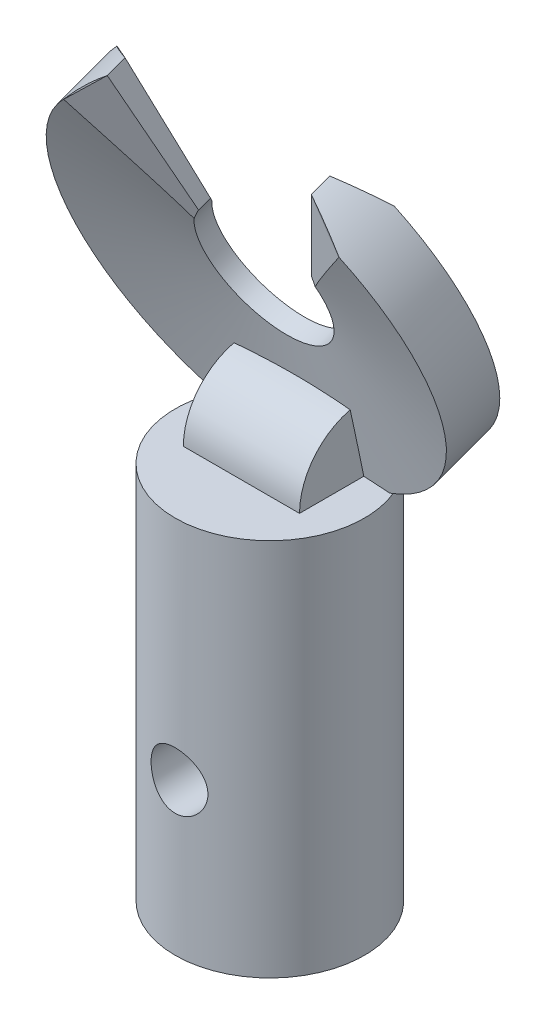
from build123d import *

# Parameters (mm, degrees)
SKETCH1_W                    = 30
SKETCH1_H                    = 30
BOSS_EXTRUDE1_DEPTH          = 3
SKETCH2_R                    = 5
BOSS_EXTRUDE2_DEPTH          = 55
CUT_EXTRUDE2_DEPTH           = 55
CUT_EXTRUDE3_DEPTH           = 7
CUT_EXTRUDE3_TAPER           = -9
CUT_EXTRUDE3_OTHER_WAY_DEPTH = 2
CUT_EXTRUDE4_DEPTH           = 7
CUT_EXTRUDE4_TAPER           = -9
CUT_EXTRUDE4_OTHER_WAY_DEPTH = 2
CUT_EXTRUDE4_OTHER_WAY_TAPER = -9
SKETCH11_W                   = 42.456870871
SKETCH11_H                   = 39.887112897
CUT_EXTRUDE5_DEPTH           = 16
CUT_EXTRUDE5_DEPTH_BACK      = 16
SKETCH12_W                   = 30
SKETCH12_H                   = 30
BOSS_EXTRUDE3_DEPTH          = 3
SKETCH13_W                   = 6.134758984
SKETCH13_H                   = 3.5
REVOLVE3_ANGLE               = 90
SKETCH14_W                   = 34.327932252
SKETCH14_H                   = 34.043423274
CUT_EXTRUDE6_DEPTH           = 3.3
SKETCH17_R                   = 2
CUT_EXTRUDE7_DEPTH           = 18
SKETCH18_R                   = 1.5
CUT_EXTRUDE8_DEPTH           = 8
CUT_EXTRUDE8_DEPTH_BACK      = 4


with BuildPart() as part:
    # Sketch1 → Boss-Extrude1 (new body)
    with BuildSketch(Plane(origin=(0, 0, 0), x_dir=(1, 0, 0), z_dir=(0, 1, 0))):
        Rectangle(SKETCH1_W, SKETCH1_H)
    extrude(amount=BOSS_EXTRUDE1_DEPTH)

    # Sketch2 → Boss-Extrude2 (add)
    with BuildSketch(Plane(origin=(0, 3, 0), x_dir=(1, 0, 0), z_dir=(0, 1, 0))):
        with Locations((0, -2)):
            Circle(SKETCH2_R)
    extrude(amount=BOSS_EXTRUDE2_DEPTH)

    # Sketch4 → Revolve1 (revolve)
    with BuildSketch(Plane(origin=(0, 0, 0), x_dir=(0, 0, -1), z_dir=(1, 0, 0))):
        Polygon((2.995694392, 58.01182956), (0.17661653, 56.98576913), (-1.106821781, 63.435791308), (-0.16712916, 63.777811451), align=None)
    revolve(axis=Axis((0, 68.333514617, -2.116247015), (0, -0.342020143, 0.939692621)))

    # Sketch5 → Cut-Extrude2 (cut)
    with BuildSketch(Plane(origin=(0, 7.748892564, -21.289907346), x_dir=(1, 0, 0), z_dir=(0, 0.342020143, -0.939692621))):
        Polygon((-3, -65.291475968), (-6.572175958, -75.105948751), (6.572175958, -75.105948751), (3, -65.291475968), align=None)
    extrude(amount=-CUT_EXTRUDE2_DEPTH, mode=Mode.SUBTRACT)

    # Sketch6 → Cut-Extrude3 (cut)
    with BuildSketch(Plane(origin=(37.638193634, 42.150337699, 15.341468287), x_dir=(0, -0.342020143, 0.939692621), z_dir=(0.64278761, 0.71984631, 0.26200263))):
        Polygon((-22.656246175, -42.076297889), (-21.656246175, -42.076297889), (-22.656246175, -39.576297889), align=None)
        Polygon((-19.616275943, -42.076297889), (-19.616275943, -39.576297889), (-20.616275943, -42.076297889), align=None)
    extrude(amount=-CUT_EXTRUDE3_DEPTH, taper=CUT_EXTRUDE3_TAPER, mode=Mode.SUBTRACT)

    # Sketch6 → Cut-Extrude3 other way (cut)
    with BuildSketch(Plane(origin=(37.638193634, 42.150337699, 15.341468287), x_dir=(0, -0.342020143, 0.939692621), z_dir=(0.64278761, 0.71984631, 0.26200263))):
        Polygon((-22.656246175, -42.076297889), (-21.656246175, -42.076297889), (-22.656246175, -39.576297889), align=None)
        Polygon((-19.616275943, -42.076297889), (-19.616275943, -39.576297889), (-20.616275943, -42.076297889), align=None)
    extrude(amount=CUT_EXTRUDE3_OTHER_WAY_DEPTH, mode=Mode.SUBTRACT)

    # Sketch8 → Cut-Extrude4 (cut)
    with BuildSketch(Plane(origin=(-37.638193634, 42.150337699, 15.341468287), x_dir=(0, 0.342020143, -0.939692621), z_dir=(0.64278761, -0.71984631, -0.26200263))):
        Polygon((22.656246175, 42.076297889), (21.656246175, 42.076297889), (22.656246175, 39.576297889), align=None)
        Polygon((20.656246175, 42.076297889), (19.656246175, 42.076297889), (19.656246175, 39.576297889), align=None)
    extrude(amount=CUT_EXTRUDE4_DEPTH, taper=CUT_EXTRUDE4_TAPER, mode=Mode.SUBTRACT)

    # Sketch8 → Cut-Extrude4 other way (cut)
    with BuildSketch(Plane(origin=(-37.638193634, 42.150337699, 15.341468287), x_dir=(0, 0.342020143, -0.939692621), z_dir=(0.64278761, -0.71984631, -0.26200263))):
        Polygon((22.656246175, 42.076297889), (21.656246175, 42.076297889), (22.656246175, 39.576297889), align=None)
        Polygon((20.656246175, 42.076297889), (19.656246175, 42.076297889), (19.656246175, 39.576297889), align=None)
    extrude(amount=-CUT_EXTRUDE4_OTHER_WAY_DEPTH, taper=CUT_EXTRUDE4_OTHER_WAY_TAPER, mode=Mode.SUBTRACT)

    # Sketch11 → Cut-Extrude5 (cut, two sides)
    with BuildSketch(Plane(origin=(0, 0, 0), x_dir=(0, 0, -1), z_dir=(1, 0, 0))) as cut_extrude5_sk:
        with Locations((2.849079493, 17.75767337)):
            Rectangle(SKETCH11_W, SKETCH11_H)
    extrude(amount=CUT_EXTRUDE5_DEPTH, mode=Mode.SUBTRACT)
    extrude(cut_extrude5_sk.sketch, amount=-CUT_EXTRUDE5_DEPTH_BACK, mode=Mode.SUBTRACT)

    # Sketch12 → Boss-Extrude3 (add)
    with BuildSketch(Plane.XZ.offset(-37.701229818)):
        Rectangle(SKETCH12_W, SKETCH12_H)
    extrude(amount=BOSS_EXTRUDE3_DEPTH)

    # Sketch13 → Revolve3 (revolve)
    with BuildSketch(Plane(origin=(0, 58, 0), x_dir=(1, 0, 0), z_dir=(0, 1, 0))):
        with Locations((0, -1.75)):
            Rectangle(SKETCH13_W, SKETCH13_H)
    revolve(axis=Axis((-3.067379492, 58, 0), (-1, 0, 0)), revolution_arc=REVOLVE3_ANGLE)

    # Sketch14 → Cut-Extrude6 (cut)
    with BuildSketch(Plane.XZ.offset(-34.701229818)):
        with Locations((-1.184585751, 0.782917941)):
            Rectangle(SKETCH14_W, SKETCH14_H)
    extrude(amount=-CUT_EXTRUDE6_DEPTH, mode=Mode.SUBTRACT)

    # Sketch17 → Cut-Extrude7 (cut)
    with BuildSketch(Plane.XZ.offset(-38.001229818)):
        with Locations((0, 2)):
            Circle(SKETCH17_R)
    extrude(amount=-CUT_EXTRUDE7_DEPTH, mode=Mode.SUBTRACT)

    # Sketch18 → Cut-Extrude8 (cut, two sides)
    with BuildSketch(Plane.XY) as cut_extrude8_sk:
        with Locations((0, 46.001229818)):
            Circle(SKETCH18_R)
    extrude(amount=CUT_EXTRUDE8_DEPTH, mode=Mode.SUBTRACT)
    extrude(cut_extrude8_sk.sketch, amount=-CUT_EXTRUDE8_DEPTH_BACK, mode=Mode.SUBTRACT)


solid = part.part
